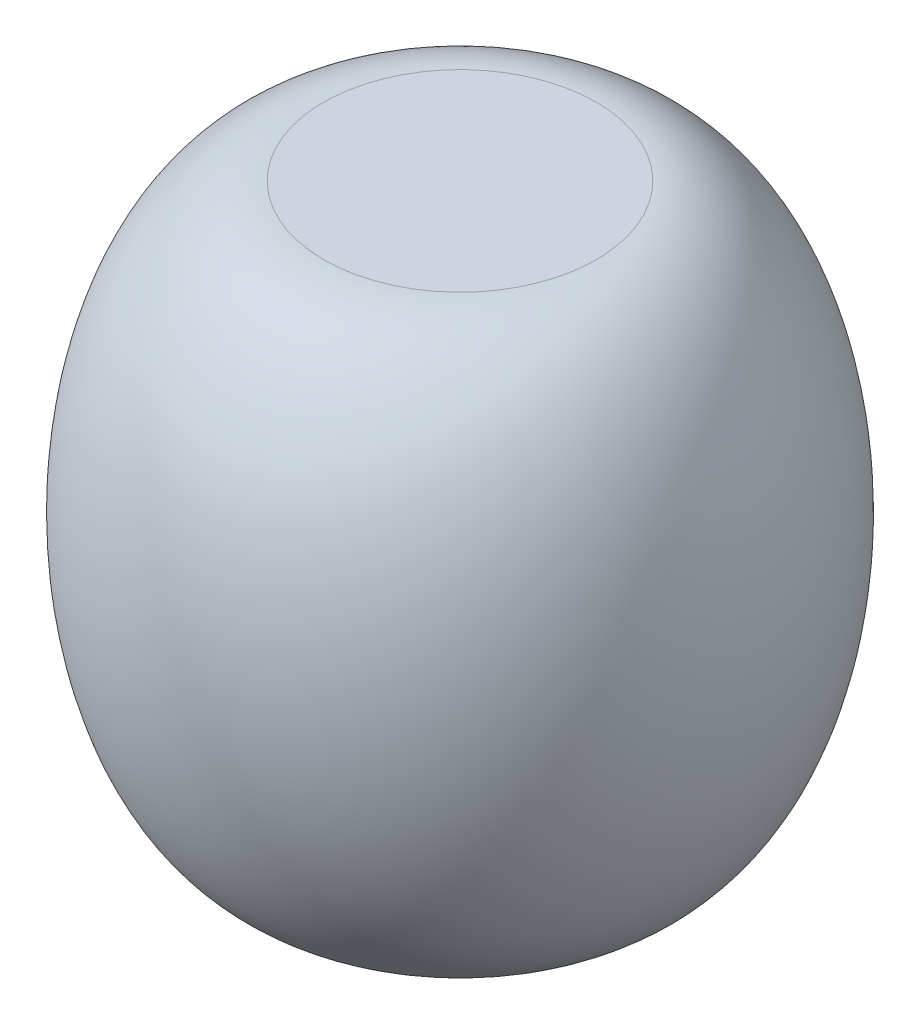
from build123d import *


with BuildPart() as part:
    # Croquis1 → Revolución1 (revolve)
    with BuildSketch(Plane.XY):
        with BuildLine():
            Line((0, 0), (0, 51))
            Line((0, 51), (12.129644262, 51))
            add(Edge.make_bspline(
                [(12.129644262, 0), (26, 0), (26, 25.499999842), (26, 50.999999684), (12.129644262, 51)],
                knots=[3.141592651, 3.141592651, 3.141592651, 4.712388972, 4.712388972, 6.283185292, 6.283185292, 6.283185292], degree=2, weights=[1, 0.707106783, 1, 0.707106783, 1]))
            Line((12.129644262, 0), (0, 0))
        make_face()
    revolve(axis=Axis((0, 0, 0), (0, 1, 0)))


solid = part.part
